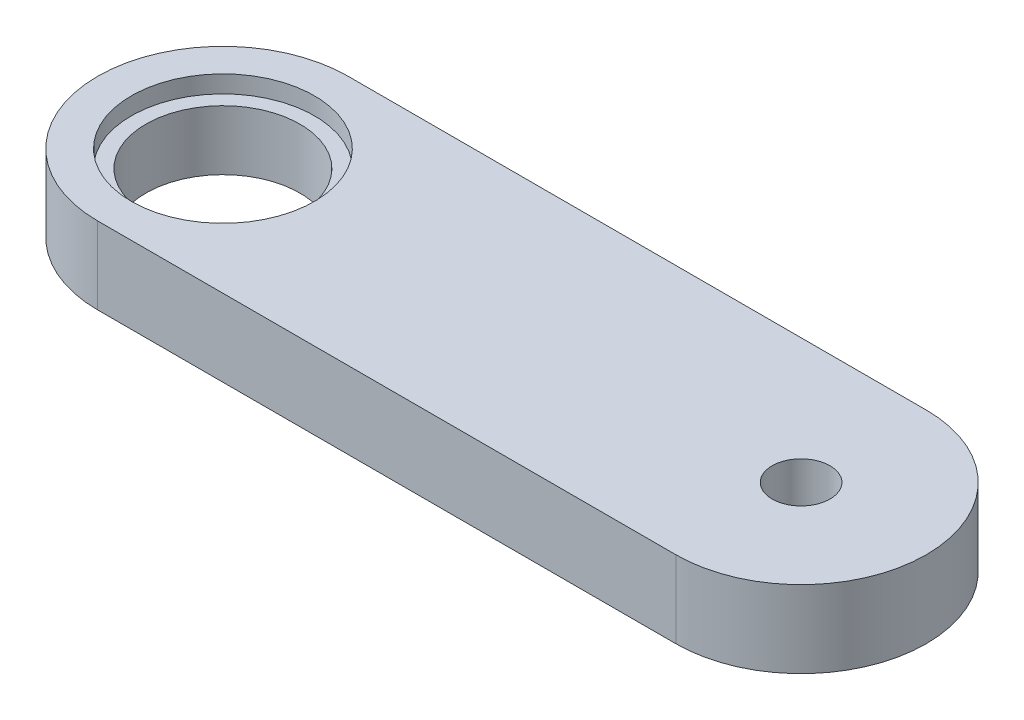
from build123d import *

# Parameters (mm, degrees)
EXTRUDE_1_DEPTH              = 4
HOLE_WIZARD_M5_1_D           = 8
HOLE_WIZARD_M5_1_DEPTH       = 12.4
HOLE_WIZARD_M5_1_CBORE_D     = 9.5
HOLE_WIZARD_M5_1_CBORE_DEPTH = 0.9
HOLE_WIZARD_M5_1_TIP         = 2.403442476
SKETCH_4_R                   = 1.5
CUT_EXTRUDE_1_DEPTH          = 1
CUT_EXTRUDE_1_DEPTH_BACK     = 5


with BuildPart() as part:
    # 草图1 → 凸台-拉伸1 (new body)
    with BuildSketch(Plane(origin=(0, 0, 0), x_dir=(1, 0, 0), z_dir=(0, 1, 0))):
        with BuildLine():
            Line((0, 6.5), (30, 6.5))
            ThreePointArc((30, 6.5), (36.5, 0), (30, -6.5))
            Line((30, -6.5), (0, -6.5))
            ThreePointArc((0, -6.5), (-6.5, 0), (0, 6.5))
        make_face()
    extrude(amount=EXTRUDE_1_DEPTH)

    # M5 六角头螺栓的柱形沉头孔1
    with Locations(Plane(origin=(0, 4, 0), x_dir=(1, 0, 0), z_dir=(0, 1, 0))):
        with Locations((0, 0)):
            CounterBoreHole(HOLE_WIZARD_M5_1_D / 2, HOLE_WIZARD_M5_1_CBORE_D / 2, HOLE_WIZARD_M5_1_CBORE_DEPTH, depth=HOLE_WIZARD_M5_1_DEPTH)
            with Locations((0, 0, -(HOLE_WIZARD_M5_1_DEPTH + HOLE_WIZARD_M5_1_TIP / 2))):  # 118° drill point
                Cone(0, HOLE_WIZARD_M5_1_D / 2, HOLE_WIZARD_M5_1_TIP, mode=Mode.SUBTRACT)

    # 草图4 → 切除-拉伸1 (cut, two sides)
    with BuildSketch(Plane(origin=(0, 4, 0), x_dir=(1, 0, 0), z_dir=(0, 1, 0))) as cut_extrude_1_sk:
        with Locations((30, 0)):
            Circle(SKETCH_4_R)
    extrude(amount=CUT_EXTRUDE_1_DEPTH, mode=Mode.SUBTRACT)
    extrude(cut_extrude_1_sk.sketch, amount=-CUT_EXTRUDE_1_DEPTH_BACK, mode=Mode.SUBTRACT)


solid = part.part
